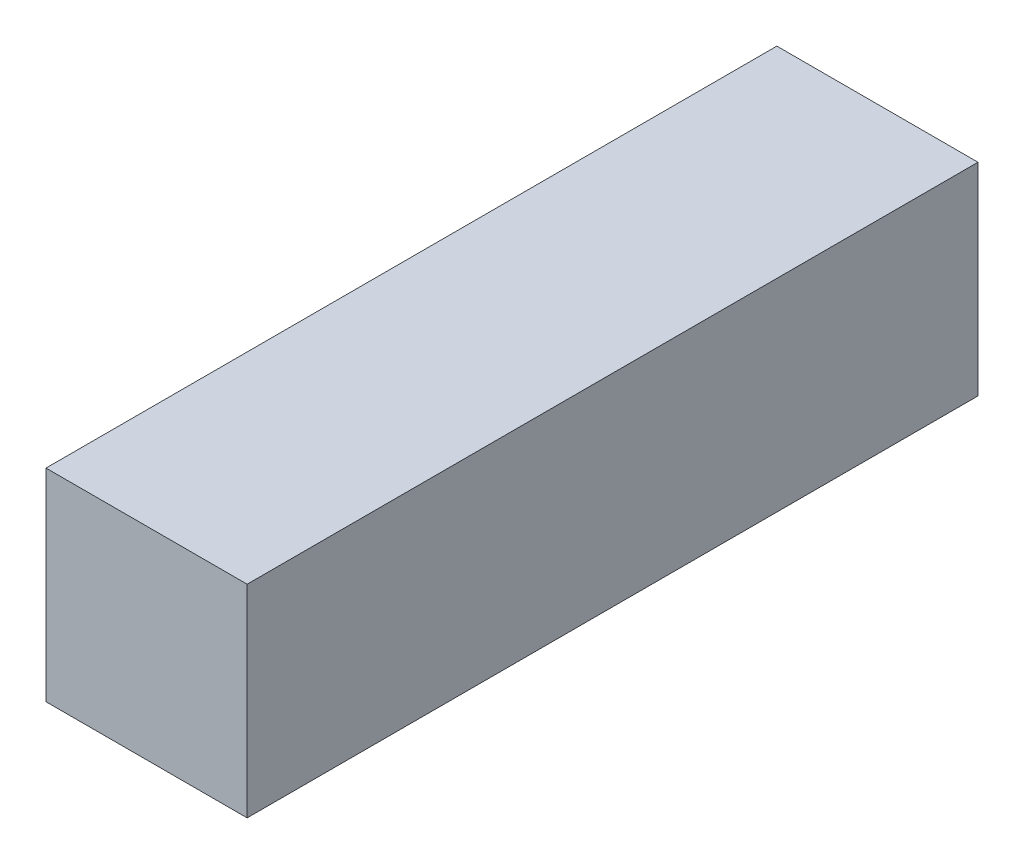
from build123d import *

# Parameters (mm, degrees)
SKETCH2_W           = 32.2
SKETCH2_H           = 32.4
BOSS_EXTRUDE1_DEPTH = 117


with BuildPart() as part:
    # Sketch2 → Boss-Extrude1 (new body)
    with BuildSketch(Plane.XY):
        Rectangle(SKETCH2_W, SKETCH2_H)
    extrude(amount=BOSS_EXTRUDE1_DEPTH)


solid = part.part
